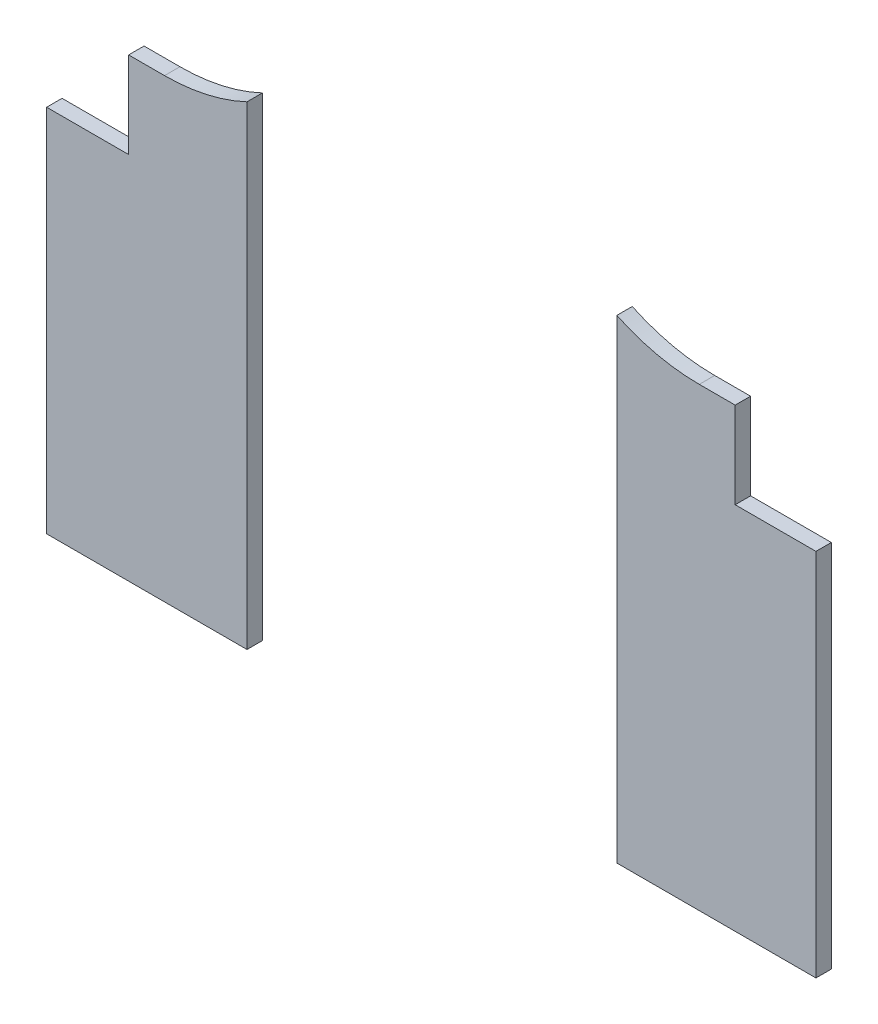
from build123d import *

# Parameters (mm, degrees)
SKETCH1_W           = 249.6
SKETCH1_H           = 267.4
BOSS_EXTRUDE1_DEPTH = 5
SKETCH5_W           = 249.6
SKETCH5_H           = 71.838779628
CUT_EXTRUDE3_DEPTH  = 6
SKETCH7_W           = 120
SKETCH7_H           = 195.561220372
CUT_EXTRUDE4_DEPTH  = 6


with BuildPart() as part:
    # Sketch1 → Boss-Extrude1 (new body)
    with BuildSketch(Plane.XY):
        with Locations((124.8, -133.7)):
            Rectangle(SKETCH1_W, SKETCH1_H)
    extrude(amount=BOSS_EXTRUDE1_DEPTH)

    # Sketch5 → Cut-Extrude3 (cut, through all)
    with BuildSketch(Plane.XY.offset(5)):
        with Locations((124.8, -231.480610186)):
            Rectangle(SKETCH5_W, SKETCH5_H)
        with BuildLine():
            Line((151.030648939, 0), (249.6, 0))
            Line((249.6, 0), (249.6, -75.685882669))
            Line((249.6, -75.685882669), (223.395661642, -75.685882669))
            Line((223.395661642, -75.685882669), (223.395661642, -47.685882669))
            Line((223.395661642, -47.685882669), (211.749607492, -47.685882669))
            ThreePointArc((211.749607492, -47.685882669), (173.146708204, -34.339378644), (151.030648939, 0))
        make_face()
        with BuildLine():
            Line((98.969351061, 0), (0, 0))
            Line((0, 0), (0, -75.685882669))
            Line((0, -75.685882669), (26.604338358, -75.685882669))
            Line((26.604338358, -75.685882669), (26.604338358, -47.685882669))
            Line((26.604338358, -47.685882669), (38.250392508, -47.685882669))
            ThreePointArc((38.250392508, -47.685882669), (76.853291796, -34.339378644), (98.969351061, 0))
        make_face()
    extrude(amount=-CUT_EXTRUDE3_DEPTH, mode=Mode.SUBTRACT)

    # Sketch7 → Cut-Extrude4 (cut, through all)
    with BuildSketch(Plane.XY.offset(5)):
        with Locations((125, -97.780610186)):
            Rectangle(SKETCH7_W, SKETCH7_H)
    extrude(amount=-CUT_EXTRUDE4_DEPTH, mode=Mode.SUBTRACT)


solid = part.part
